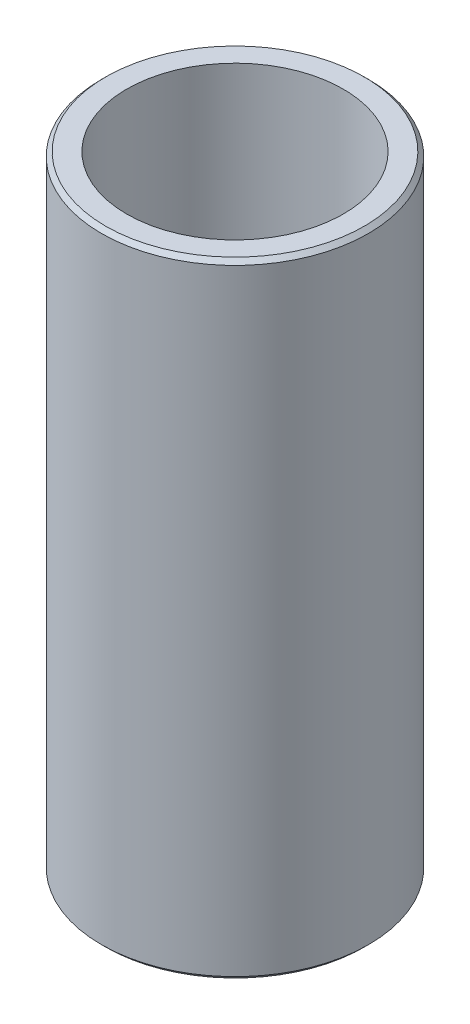
from build123d import *

# Parameters (mm, degrees)
SKETCH1_R           = 7.94
SKETCH1_R_2         = 6.44
BOSS_EXTRUDE1_DEPTH = 37.13
CHAMFER1_SIZE       = 0.25


with BuildPart() as part:
    # Sketch1 → Boss-Extrude1 (new body)
    with BuildSketch(Plane(origin=(0, 0, 0), x_dir=(1, 0, 0), z_dir=(0, 1, 0))):
        Circle(SKETCH1_R)
        Circle(SKETCH1_R_2, mode=Mode.SUBTRACT)
    extrude(amount=BOSS_EXTRUDE1_DEPTH)

    # Chamfer1
    chamfer1_edges = [part.edges().sort_by_distance(p)[0] for p in [
        (-7.94, 0, 0),
        (-7.94, 37.13, 0),
    ]]
    chamfer(chamfer1_edges, length=CHAMFER1_SIZE)


solid = part.part
